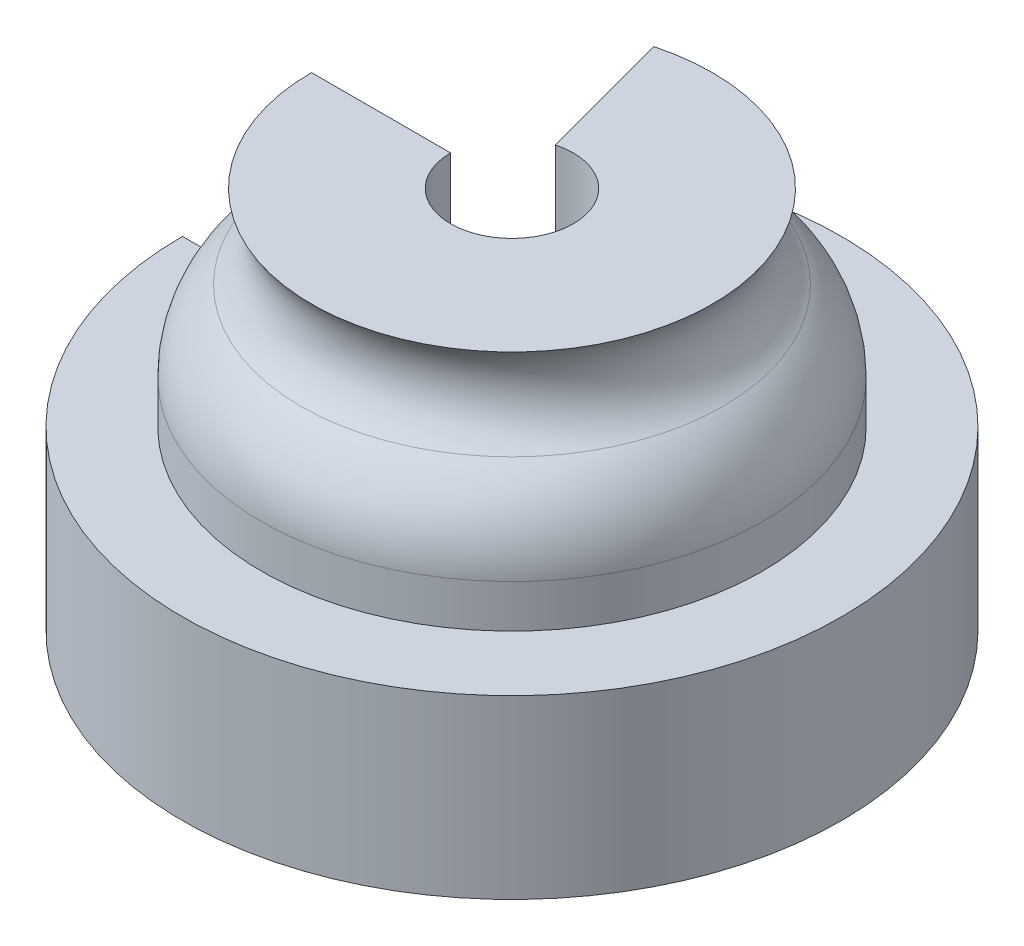
from build123d import *

# Parameters (mm, degrees)
REVOLVE_THIN1_ANGLE = 285


with BuildPart() as part:
    # Sketch1 → Revolve-Thin1 (revolve)
    with BuildSketch(Plane.XY):
        with BuildLine():
            Line((-27.538484773, 20.124551934), (-27.538484773, 15.403929488))
            Line((-27.538484773, 15.403929488), (-36.227206247, 15.403929488))
            Line((-36.227206247, 15.403929488), (-36.227206247, -4))
            Line((-36.227206247, -4), (-6.746755937, -4))
            Line((-6.746755937, -4), (-6.746755937, 38.091146669))
            Line((-6.746755937, 38.091146669), (-22.039284373, 38.091146669))
            ThreePointArc((-22.039284373, 38.091146669), (-20.717051221, 33.270500036), (-23.203151183, 28.933883676))
            ThreePointArc((-23.203151183, 28.933883676), (-26.395944189, 25.033712837), (-27.538484773, 20.124551934))
        make_face()
        with BuildLine():
            Line((-23.538484773, 20.124551934), (-23.538484773, 11.403929488))
            Line((-23.538484773, 11.403929488), (-32.227206247, 11.403929488))
            Line((-32.227206247, 11.403929488), (-32.227206247, 0))
            Line((-32.227206247, 0), (-10.746755937, 0))
            Line((-10.746755937, 0), (-10.746755937, 34.091146669))
            Line((-10.746755937, 34.091146669), (-16.665109009, 34.091146669))
            ThreePointArc((-16.665109009, 34.091146669), (-17.745052772, 29.450945899), (-20.762920969, 25.764455257))
            ThreePointArc((-20.762920969, 25.764455257), (-22.807008354, 23.267491001), (-23.538484773, 20.124551934))
        make_face(mode=Mode.SUBTRACT)
    revolve(axis=Axis((0, 0, 0), (0, 1, 0)), revolution_arc=REVOLVE_THIN1_ANGLE)


solid = part.part
